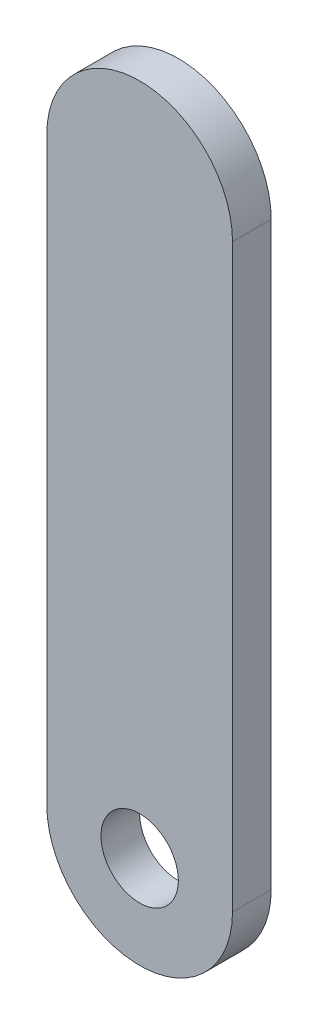
from build123d import *

# Parameters (mm, degrees)
ESBO_O1_R                = 5
RESSALTO_EXTRUS_O1_DEPTH = 5


with BuildPart() as part:
    # Esboço1 → Ressalto-extrusão1 (new body)
    with BuildSketch(Plane.XY):
        with BuildLine():
            Line((-12, 0), (-12, 75))
            ThreePointArc((-12, 75), (0, 87), (12, 75))
            Line((12, 75), (12, 0))
            ThreePointArc((12, 0), (0, -12), (-12, 0))
        make_face()
        Circle(ESBO_O1_R, mode=Mode.SUBTRACT)
    extrude(amount=RESSALTO_EXTRUS_O1_DEPTH)


solid = part.part
